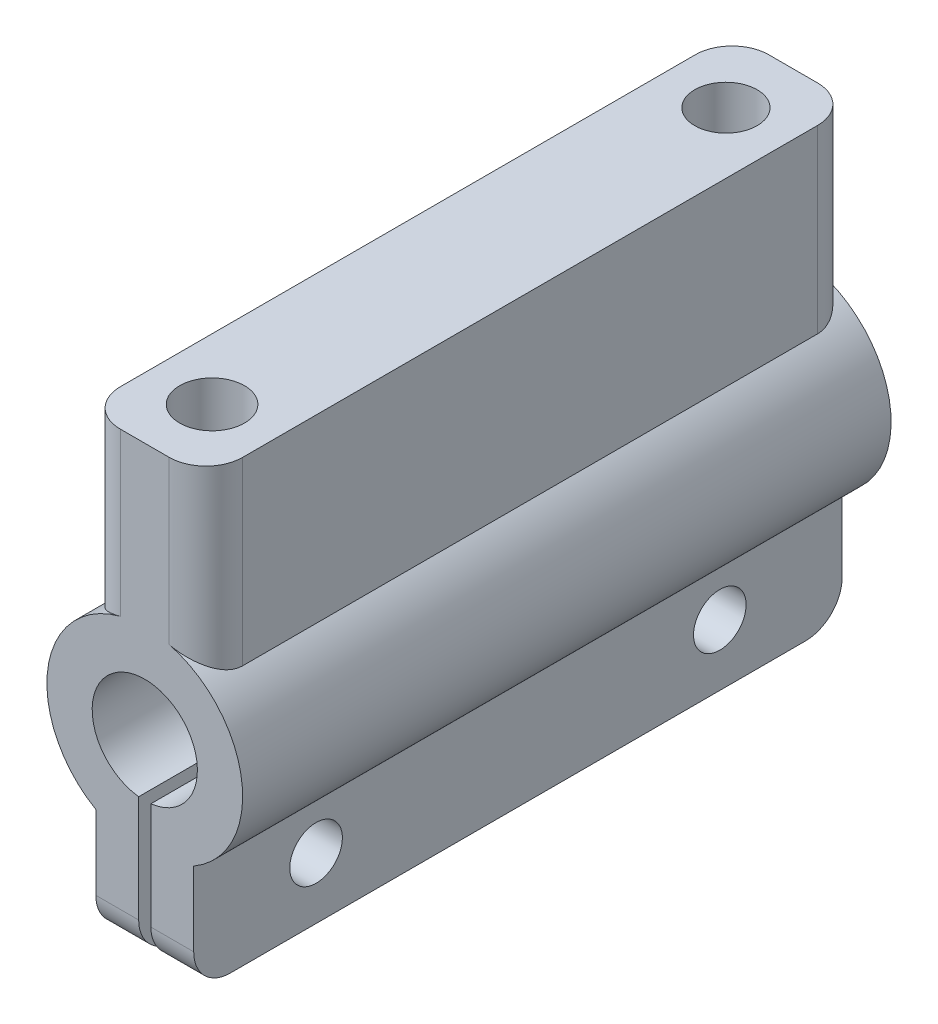
from build123d import *

# Parameters (mm, degrees)
BOSS_EXTRUDE1_DEPTH = 53
SKETCH2_R           = 2.15
CUT_EXTRUDE1_DEPTH  = 40
SKETCH3_R           = 2.55
SKETCH3_R_2         = 2.65
CUT_EXTRUDE2_DEPTH  = 7
FILLET1_R           = 3


with BuildPart() as part:
    # Sketch1 → Boss-Extrude1 (new body)
    with BuildSketch(Plane.XY):
        with BuildLine():
            Line((-9, 45.999997998), (-9, 31.244997998))
            ThreePointArc((-9, 31.244997998), (-4, 33), (1, 31.244997998))
            Line((1, 31.244997998), (1, 45.999997998))
            Line((1, 45.999997998), (-9, 45.999997998))
        make_face()
        with BuildLine():
            ThreePointArc((1, 31.244997998), (-4, 33), (-9, 31.244997998))
            Line((-9, 31.244997998), (1, 31.244997998))
        make_face()
        with BuildLine():
            Line((-8, 18.07179677), (-8, 23.422026616))
            ThreePointArc((-8, 23.422026616), (-4.80311892, 29.224334267), (0.3, 25))
            ThreePointArc((0.3, 25), (0.224334267, 24.19688108), (0, 23.422026616))
            Line((0, 23.422026616), (0, 18.07179677))
            ThreePointArc((0, 18.07179677), (2.92820323, 21), (4, 25))
            ThreePointArc((4, 25), (3.211102551, 28.464101615), (1, 31.244997998))
            Line((1, 31.244997998), (-9, 31.244997998))
            ThreePointArc((-9, 31.244997998), (-11.977048806, 24.394448725), (-8, 18.07179677))
        make_face()
        with BuildLine():
            ThreePointArc((0, 23.422026616), (-1.377907145, 21.591975784), (-3.5, 20.729168699))
            Line((-3.5, 20.729168699), (-3.5, 17.015640289))
            ThreePointArc((-3.5, 17.015640289), (-1.688860318, 17.341107562), (0, 18.07179677))
            Line((0, 18.07179677), (0, 23.422026616))
        make_face()
        with BuildLine():
            ThreePointArc((-4.5, 20.729168699), (-6.622092855, 21.591975784), (-8, 23.422026616))
            Line((-8, 23.422026616), (-8, 18.07179677))
            ThreePointArc((-8, 18.07179677), (-6.311139682, 17.341107562), (-4.5, 17.015640289))
            Line((-4.5, 17.015640289), (-4.5, 20.729168699))
        make_face()
        with BuildLine():
            ThreePointArc((-4.5, 17.015640289), (-6.311139682, 17.341107562), (-8, 18.07179677))
            Line((-8, 18.07179677), (-8, 9))
            Line((-8, 9), (-4.5, 9))
            Line((-4.5, 9), (-4.5, 17.015640289))
        make_face()
        with BuildLine():
            ThreePointArc((0, 18.07179677), (-1.688860318, 17.341107562), (-3.5, 17.015640289))
            Line((-3.5, 17.015640289), (-3.5, 9))
            Line((-3.5, 9), (0, 9))
            Line((0, 9), (0, 18.07179677))
        make_face()
    extrude(amount=BOSS_EXTRUDE1_DEPTH)

    # Sketch2 → Cut-Extrude1 (cut)
    with BuildSketch(Plane(origin=(0, 0, 0), x_dir=(0, 0, -1), z_dir=(1, 0, 0))):
        with Locations((-43, 14)):
            Circle(SKETCH2_R)
        with Locations((-10, 14)):
            Circle(SKETCH2_R)
    extrude(amount=-CUT_EXTRUDE1_DEPTH, mode=Mode.SUBTRACT)

    # Sketch3 → Cut-Extrude2 (cut)
    with BuildSketch(Plane(origin=(0, 45.999997998, 0), x_dir=(1, 0, 0), z_dir=(0, 1, 0))):
        with Locations((-4, -5.5)):
            Circle(SKETCH3_R)
        with Locations((-4, -47.5)):
            Circle(SKETCH3_R_2)
    extrude(amount=-CUT_EXTRUDE2_DEPTH, mode=Mode.SUBTRACT)

    # Fillet1
    fillet1_edges = [part.edges().sort_by_distance(p)[0] for p in [
        (1, 38.622497998, 0),
        (-1.75, 9, 0),
        (-6.25, 9, 0),
        (-9, 38.622497998, 0),
        (-6.25, 9, 53),
        (-1.75, 9, 53),
        (-9, 38.622497998, 53),
        (1, 38.622497998, 53),
    ]]
    fillet(fillet1_edges, radius=FILLET1_R)


solid = part.part
